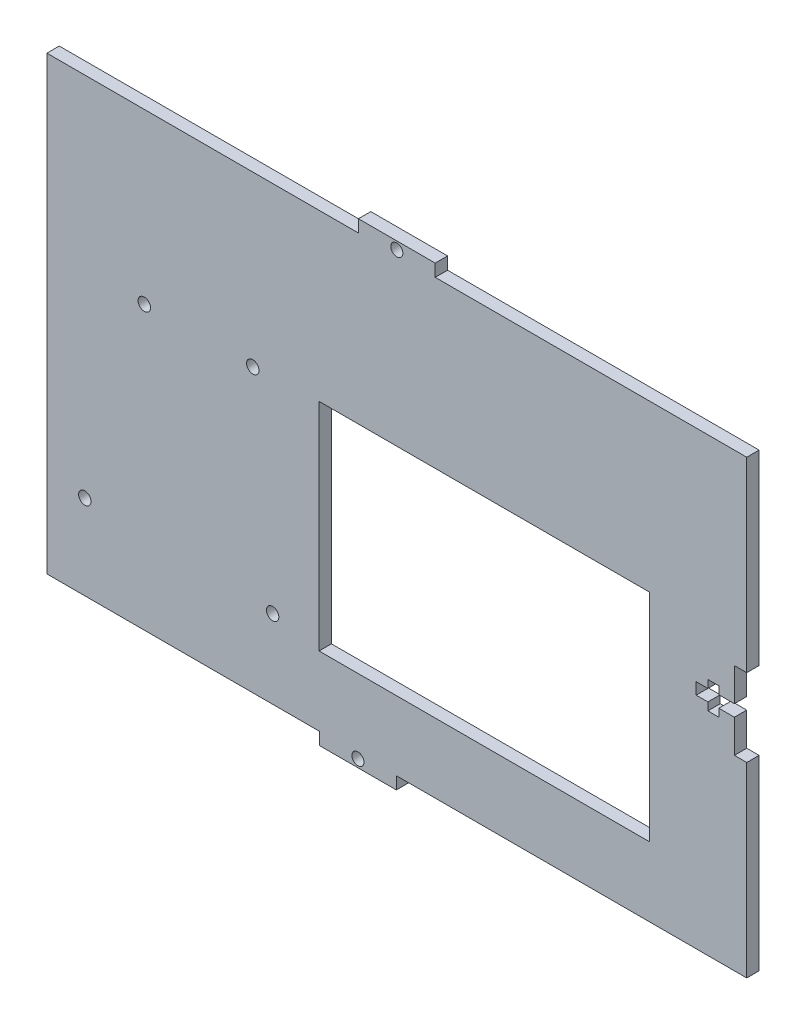
from build123d import *

# Parameters (mm, degrees)
SKETCH1_W               = 180
SKETCH1_H               = 122.36
BOSS_EXTRUDE1_DEPTH     = 3.18
CUT_EXTRUDE1_DEPTH      = 1
CUT_EXTRUDE1_DEPTH_BACK = 4.18
SKETCH3_W               = 70.125
SKETCH3_H               = 3.18
SKETCH3_W_2             = 90.125
CUT_EXTRUDE2_DEPTH      = 1
CUT_EXTRUDE2_DEPTH_BACK = 4.18
SKETCH4_R               = 1.55
CUT_EXTRUDE3_DEPTH      = 1
CUT_EXTRUDE3_DEPTH_BACK = 4.18
SKETCH6_R               = 1.6
CUT_EXTRUDE4_DEPTH      = 1
CUT_EXTRUDE4_DEPTH_BACK = 4.18
SKETCH7_W               = 85
SKETCH7_H               = 55.6
CUT_EXTRUDE5_DEPTH      = 1
CUT_EXTRUDE5_DEPTH_BACK = 4.18
SKETCH8_W               = 80.125
SKETCH8_H               = 3.18
CUT_EXTRUDE6_DEPTH      = 1
CUT_EXTRUDE6_DEPTH_BACK = 4.18
SKETCH9_R               = 1.55
CUT_EXTRUDE7_DEPTH      = 1
CUT_EXTRUDE7_DEPTH_BACK = 4.18


with BuildPart() as part:
    # Sketch1 → Boss-Extrude1 (new body)
    with BuildSketch(Plane.XY):
        Rectangle(SKETCH1_W, SKETCH1_H)
    extrude(amount=BOSS_EXTRUDE1_DEPTH)

    # Sketch2 → Cut-Extrude1 (cut, two sides)
    with BuildSketch(Plane.XY.offset(3.18)) as cut_extrude1_sk:
        Polygon((80, 1.5), (77, 1.5), (77, -1.5), (80, -1.5), (80, -3.5), (82.82, -3.5), (82.82, -1.5), (86.82, -1.5), (86.82, -10), (90, -10), (90, 10), (86.82, 10), (86.82, 1.5), (82.82, 1.5), (82.82, 3.5), (80, 3.5), align=None)
    extrude(amount=CUT_EXTRUDE1_DEPTH, mode=Mode.SUBTRACT)
    extrude(cut_extrude1_sk.sketch, amount=-CUT_EXTRUDE1_DEPTH_BACK, mode=Mode.SUBTRACT)

    # Sketch3 → Cut-Extrude2 (cut, two sides)
    with BuildSketch(Plane.XY.offset(3.18)) as cut_extrude2_sk:
        with Locations((-54.9375, -59.59)):
            Rectangle(SKETCH3_W, SKETCH3_H)
        with Locations((44.9375, -59.59)):
            Rectangle(SKETCH3_W_2, SKETCH3_H)
    extrude(amount=CUT_EXTRUDE2_DEPTH, mode=Mode.SUBTRACT)
    extrude(cut_extrude2_sk.sketch, amount=-CUT_EXTRUDE2_DEPTH_BACK, mode=Mode.SUBTRACT)

    # Sketch4 → Cut-Extrude3 (cut, two sides)
    with BuildSketch(Plane.XY.offset(3.18)) as cut_extrude3_sk:
        with Locations((-10, -59.18)):
            Circle(SKETCH4_R)
    extrude(amount=CUT_EXTRUDE3_DEPTH, mode=Mode.SUBTRACT)
    extrude(cut_extrude3_sk.sketch, amount=-CUT_EXTRUDE3_DEPTH_BACK, mode=Mode.SUBTRACT)

    # Sketch6 → Cut-Extrude4 (cut, two sides)
    with BuildSketch(Plane.XY.offset(3.18)) as cut_extrude4_sk:
        with Locations((-64.946313591, 14.6)):
            Circle(SKETCH6_R)
        with Locations((-80.246313591, -36.2)):
            Circle(SKETCH6_R)
        with Locations((-31.946313591, -37.8)):
            Circle(SKETCH6_R)
        with Locations((-37.046313591, 14.6)):
            Circle(SKETCH6_R)
    extrude(amount=CUT_EXTRUDE4_DEPTH, mode=Mode.SUBTRACT)
    extrude(cut_extrude4_sk.sketch, amount=-CUT_EXTRUDE4_DEPTH_BACK, mode=Mode.SUBTRACT)

    # Sketch7 → Cut-Extrude5 (cut, two sides)
    with BuildSketch(Plane(origin=(0, 0, 0), x_dir=(-1, 0, 0), z_dir=(0, 0, -1))) as cut_extrude5_sk:
        with Locations((-22.5, -12.359811841)):
            Rectangle(SKETCH7_W, SKETCH7_H)
    extrude(amount=CUT_EXTRUDE5_DEPTH, mode=Mode.SUBTRACT)
    extrude(cut_extrude5_sk.sketch, amount=-CUT_EXTRUDE5_DEPTH_BACK, mode=Mode.SUBTRACT)

    # Sketch8 → Cut-Extrude6 (cut, two sides)
    with BuildSketch(Plane.XY.offset(3.18)) as cut_extrude6_sk:
        with Locations((-49.9375, 59.59)):
            Rectangle(SKETCH8_W, SKETCH8_H)
        with Locations((49.9375, 59.59)):
            Rectangle(SKETCH8_W, SKETCH8_H)
    extrude(amount=CUT_EXTRUDE6_DEPTH, mode=Mode.SUBTRACT)
    extrude(cut_extrude6_sk.sketch, amount=-CUT_EXTRUDE6_DEPTH_BACK, mode=Mode.SUBTRACT)

    # Sketch9 → Cut-Extrude7 (cut, two sides)
    with BuildSketch(Plane.XY.offset(3.18)) as cut_extrude7_sk:
        with Locations((0, 59.18)):
            Circle(SKETCH9_R)
    extrude(amount=CUT_EXTRUDE7_DEPTH, mode=Mode.SUBTRACT)
    extrude(cut_extrude7_sk.sketch, amount=-CUT_EXTRUDE7_DEPTH_BACK, mode=Mode.SUBTRACT)


solid = part.part
